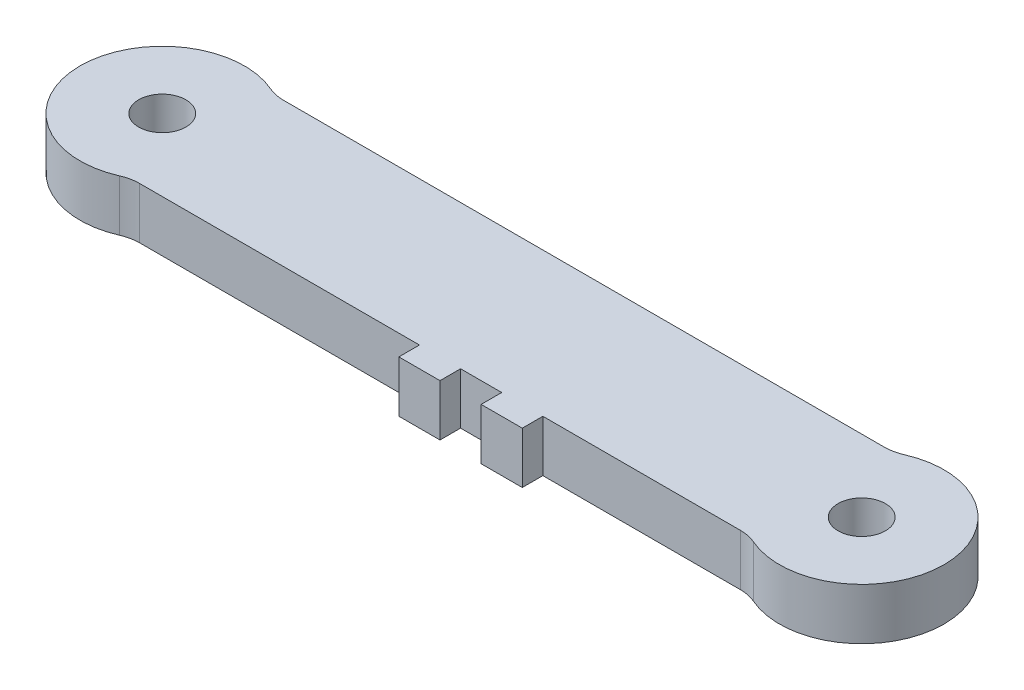
from build123d import *

# Parameters (mm, degrees)
SKETCH1_R           = 5.08
SKETCH1_R_2         = 1.4605
BOSS_EXTRUDE1_DEPTH = 3.175
FILLET1_R           = 2.54
SKETCH2_W           = 2.54
SKETCH2_H           = 3.175
BOSS_EXTRUDE2_DEPTH = 1.27


with BuildPart() as part:
    # Sketch1 → Boss-Extrude1 (new body)
    with BuildSketch(Plane(origin=(0, 0, 0), x_dir=(1, 0, 0), z_dir=(0, 1, 0))):
        Circle(SKETCH1_R)
        Circle(SKETCH1_R_2, mode=Mode.SUBTRACT)
        with BuildLine():
            Line((40.720655575, 4.445), (2.459344425, 4.445))
            ThreePointArc((2.459344425, 4.445), (4.376063852, 2.580012628), (5.08, 0))
            ThreePointArc((5.08, 0), (4.376063852, -2.580012628), (2.459344425, -4.445))
            Line((2.459344425, -4.445), (40.720655575, -4.445))
            ThreePointArc((40.720655575, -4.445), (38.1, 0), (40.720655575, 4.445))
        make_face()
        with Locations((43.18, 0)):
            Circle(SKETCH1_R)
        with Locations((43.18, 0)):
            Circle(SKETCH1_R_2, mode=Mode.SUBTRACT)
    extrude(amount=BOSS_EXTRUDE1_DEPTH)

    # Fillet1
    fillet1_edges = [part.edges().sort_by_distance(p)[0] for p in [
        (2.459344425, 1.5875, -4.445),
        (40.720655575, 1.5875, -4.445),
        (40.720655575, 1.5875, 4.445),
        (2.459344425, 1.5875, 4.445),
    ]]
    fillet(fillet1_edges, radius=FILLET1_R)

    # Sketch2 → Boss-Extrude2 (add)
    with BuildSketch(Plane.XY.offset(4.445)):
        with Locations((26.67, 1.5875)):
            Rectangle(SKETCH2_W, SKETCH2_H)
        with Locations((21.59, 1.5875)):
            Rectangle(SKETCH2_W, SKETCH2_H)
    extrude(amount=BOSS_EXTRUDE2_DEPTH)


solid = part.part
